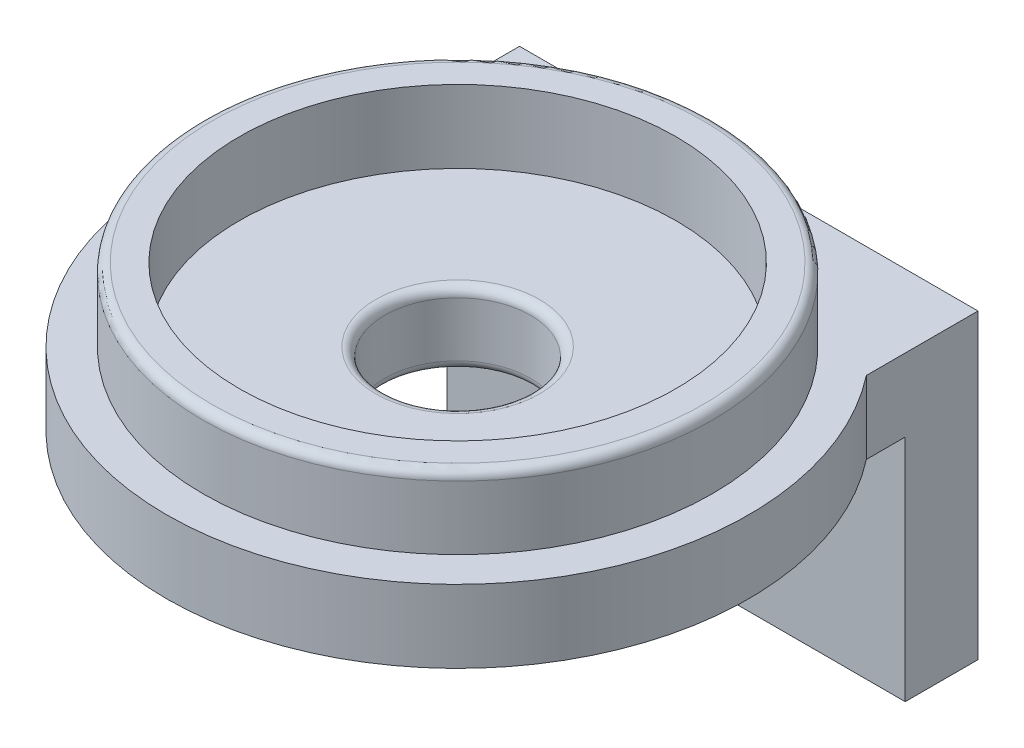
from build123d import *

# Parameters (mm, degrees)
FILLET1_R           = 0.79375
BOSS_EXTRUDE1_DEPTH = 20
CUT_EXTRUDE1_DEPTH  = 7.35


with BuildPart() as part:
    # Sketch1 → Revolve1 (revolve)
    with BuildSketch(Plane(origin=(0, 0, 0), x_dir=(0, 0, -1), z_dir=(1, 0, 0))):
        Polygon((22.225, 9.525), (22.225, 3.175), (25.4, 3.175), (25.4, -3.175), (6.35, -3.175), (6.35, 3.175), (19.05, 3.175), (19.05, 9.525), align=None)
    revolve(axis=Axis((0, -32.325211936, 0), (0, 1, 0)))

    # Fillet1
    fillet1_edges = [part.edges().sort_by_distance(p)[0] for p in [
        (0, 9.525, 22.225),
        (0, 3.175, 6.35),
        (0, -3.175, 6.35),
    ]]
    fillet(fillet1_edges, radius=FILLET1_R)

    # Sketch2 → Boss-Extrude1 (add, symmetric)
    with BuildSketch(Plane(origin=(0, 0, 0), x_dir=(0, 0, -1), z_dir=(1, 0, 0))):
        Polygon((25.4, 3.175), (12.7, 3.175), (12.7, -3.175), (19.05, -3.175), (19.05, -23.174999878), (25.4, -23.174999878), (25.4, -3.175), align=None)
    extrude(amount=BOSS_EXTRUDE1_DEPTH, both=True)

    # Sketch3 → Cut-Extrude1 (cut, through all)
    with BuildSketch(Plane.XY.offset(-19.05)):
        with BuildLine():
            ThreePointArc((-10, -11.075), (-12.1, -13.175), (-10, -15.275))
            ThreePointArc((-10, -15.275), (-8.51507576, -14.65992424), (-7.9, -13.175))
            ThreePointArc((-7.9, -13.175), (-8.51507576, -11.69007576), (-10, -11.075))
        make_face()
        with BuildLine():
            ThreePointArc((10, -11.075), (7.9, -13.175), (10, -15.275))
            ThreePointArc((10, -15.275), (11.48492424, -14.65992424), (12.1, -13.175))
            ThreePointArc((12.1, -13.175), (11.48492424, -11.69007576), (10, -11.075))
        make_face()
    extrude(amount=-CUT_EXTRUDE1_DEPTH, mode=Mode.SUBTRACT)


solid = part.part
